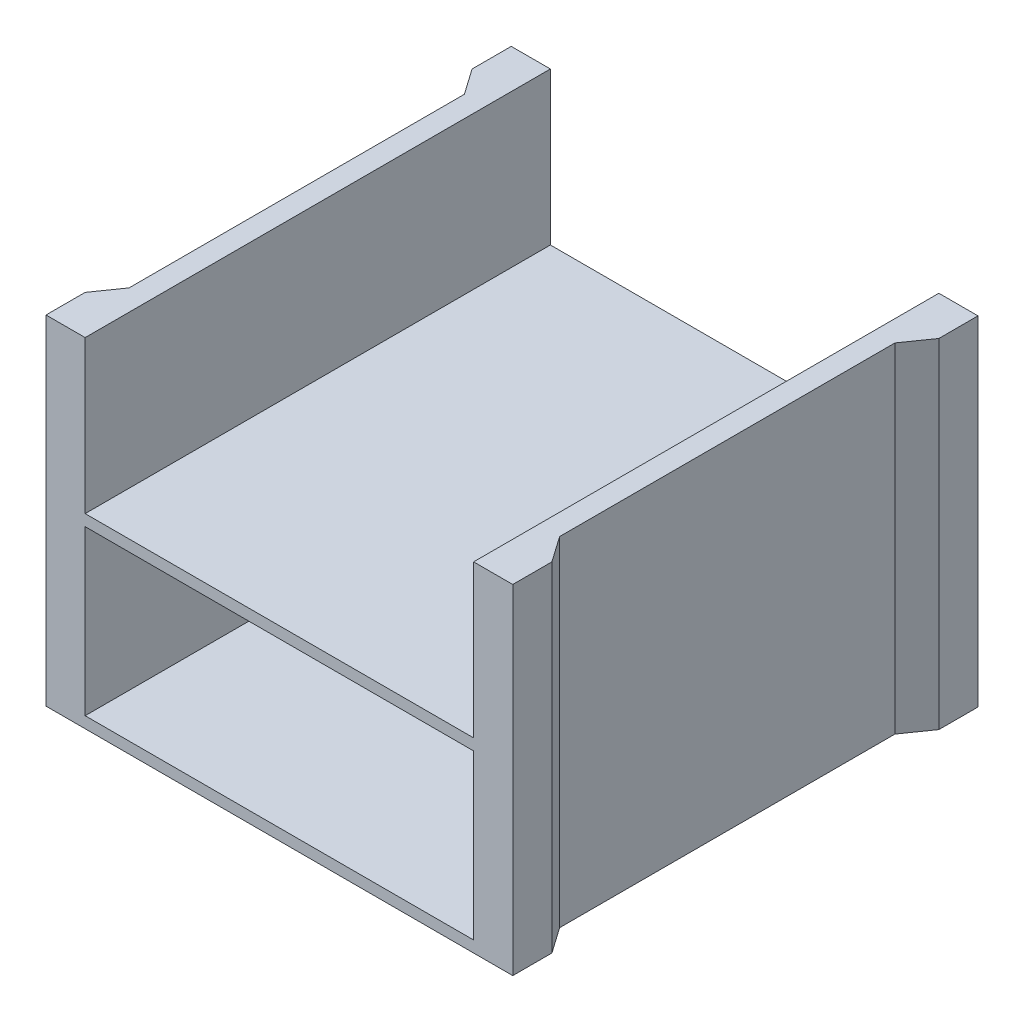
from build123d import *

# Parameters (mm, degrees)
SKETCH1_W           = 6.096
SKETCH1_H           = 13.208
BOSS_EXTRUDE1_DEPTH = 114.3
SKETCH3_W           = 131.064
SKETCH3_H           = 55.245
SKETCH3_H_2         = 51.435
CUT_EXTRUDE2_DEPTH  = 304.8
BOSS_EXTRUDE2_DEPTH = 114.3


with BuildPart() as part:
    # Sketch1 → Boss-Extrude1 (new body)
    with BuildSketch(Plane(origin=(0, 0, 0), x_dir=(1, 0, 0), z_dir=(0, 1, 0))):
        Polygon((72.644, 78.486), (0, 78.486), (0, 0), (72.644, 0), (72.644, 56.572009751), (72.644, 65.278), align=None)
        with Locations((75.692, 71.882)):
            Rectangle(SKETCH1_W, SKETCH1_H)
        Polygon((72.644, 0), (0, 0), (0, -78.486), (72.644, -78.486), (72.644, -65.278), (72.644, -56.572009751), align=None)
        Polygon((0, -78.486), (0, 0), (-72.644, 0), (-72.644, -56.572009751), (-72.644, -65.278), (-72.644, -78.486), align=None)
        with Locations((-75.692, -71.882)):
            Rectangle(SKETCH1_W, SKETCH1_H)
        Polygon((0, 0), (0, 78.486), (-72.644, 78.486), (-72.644, 65.278), (-72.644, 56.572009751), (-72.644, 0), align=None)
        with Locations((-75.692, 71.882)):
            Rectangle(SKETCH1_W, SKETCH1_H)
        with Locations((75.692, -71.882)):
            Rectangle(SKETCH1_W, SKETCH1_H)
    extrude(amount=BOSS_EXTRUDE1_DEPTH)

    # Sketch3 → Cut-Extrude2 (cut)
    with BuildSketch(Plane.XY.offset(78.486)):
        with Locations((0, 31.4325)):
            Rectangle(SKETCH3_W, SKETCH3_H)
        with Locations((0, 88.5825)):
            Rectangle(SKETCH3_W, SKETCH3_H_2)
    extrude(amount=-CUT_EXTRUDE2_DEPTH, mode=Mode.SUBTRACT)

    # Sketch4 → Boss-Extrude2 (add)
    with BuildSketch(Plane.XZ):
        Polygon((-78.74, 65.278), (-72.644, 65.278), (-72.644, 56.572009751), align=None)
        Polygon((-72.644, -65.278), (-78.74, -65.278), (-72.644, -56.572009751), align=None)
        Polygon((72.644, -65.278), (72.644, -56.572009751), (78.74, -65.278), align=None)
        Polygon((72.644, 56.572009751), (72.644, 65.278), (78.74, 65.278), align=None)
    extrude(amount=-BOSS_EXTRUDE2_DEPTH)


solid = part.part
